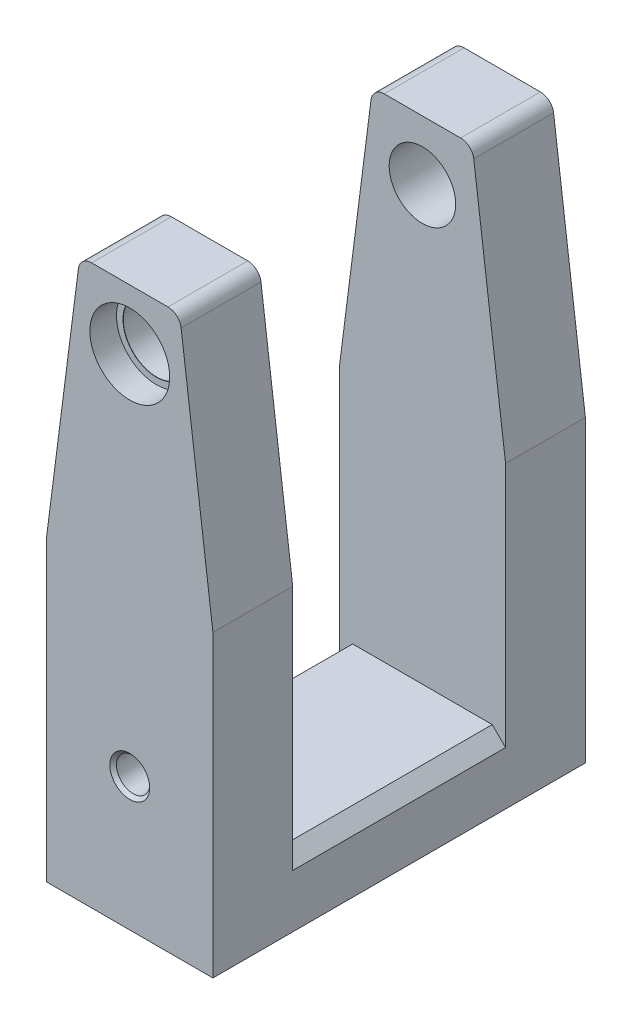
from build123d import *

# Parameters (mm, degrees)
BOSS_EXTRUDE3_DEPTH         = 28
SKETCH4_W                   = 32
SKETCH4_H                   = 74
CUT_EXTRUDE2_DEPTH          = 26
M6_TAPPED_HOLE1_D           = 5
M6_TAPPED_HOLE1_DEPTH       = 27
M6_TAPPED_HOLE1_CSINK_D     = 6
M6_TAPPED_HOLE1_CSINK_ANGLE = 90
M6_TAPPED_HOLE1_TIP         = 1.502151548
CHAMFER1_SIZE               = 2
FILLET2_R                   = 2


with BuildPart() as part:
    # Sketch3 → Boss-Extrude3 (new body, symmetric)
    with BuildSketch(Plane.XY):
        Polygon((12.5, 0), (-12.5, 0), (-12.5, 45), (-7.5, 84), (7.5, 84), (12.5, 45), align=None)
    extrude(amount=BOSS_EXTRUDE3_DEPTH, both=True)

    # Sketch4 → Cut-Extrude2 (cut, through all)
    with BuildSketch(Plane(origin=(12.5, 0, 0), x_dir=(0, 0, -1), z_dir=(1, 0, 0))):
        with Locations((0, 47)):
            Rectangle(SKETCH4_W, SKETCH4_H)
    extrude(amount=-CUT_EXTRUDE2_DEPTH, mode=Mode.SUBTRACT)

    # Sketch7 → CBORE for M4 Hex Socket Head Cap Screw1 (revolve, cut)
    with BuildSketch(Plane(origin=(0, 75, 28), x_dir=(0, -1, 0), z_dir=(1, 0, 0))):
        Polygon((0, 0), (0, 23.004303095), (5, 20), (5, 4.025), (5.025, 4), (6, 4), (6, 0), align=None)
    cbore_for_m4_hex_socket_head_cap_screw1 = revolve(axis=Axis((0, 75, 34.35), (0, 0, -1)), mode=Mode.SUBTRACT)

    # Mirror1: CBORE for M4 Hex Socket Head Cap Screw1 across plane
    add(cbore_for_m4_hex_socket_head_cap_screw1.mirror(Plane.XY), mode=Mode.SUBTRACT)

    # M6 Tapped Hole1
    with Locations(Plane.XY.offset(28)):
        with Locations((0, 20)):
            CounterSinkHole(M6_TAPPED_HOLE1_D / 2, M6_TAPPED_HOLE1_CSINK_D / 2, depth=M6_TAPPED_HOLE1_DEPTH, counter_sink_angle=M6_TAPPED_HOLE1_CSINK_ANGLE)
            with Locations((0, 0, -(M6_TAPPED_HOLE1_DEPTH + M6_TAPPED_HOLE1_TIP / 2))):  # 118° drill point
                Cone(0, M6_TAPPED_HOLE1_D / 2, M6_TAPPED_HOLE1_TIP, mode=Mode.SUBTRACT)

    # Chamfer1
    chamfer1_edges = [part.edges().sort_by_distance(p)[0] for p in [
        (12.5, 10, 0),
        (-12.5, 10, 0),
    ]]
    chamfer(chamfer1_edges, length=CHAMFER1_SIZE)

    # Fillet2
    fillet2_edges = [part.edges().sort_by_distance(p)[0] for p in [
        (-7.5, 84, 22),
        (7.5, 84, 22),
        (-7.5, 84, -22),
        (7.5, 84, -22),
    ]]
    fillet(fillet2_edges, radius=FILLET2_R)


solid = part.part
